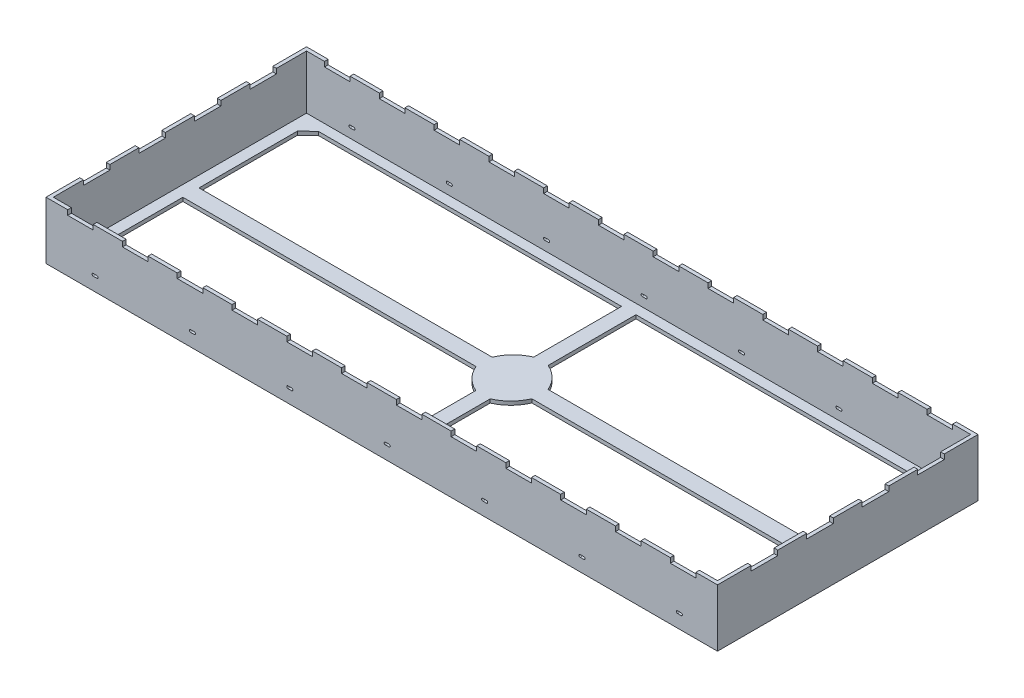
from build123d import *

# Parameters (mm, degrees)
SKETCH1_W           = 70.0532
SKETCH1_H           = 27.178
BOSS_EXTRUDE1_DEPTH = 5.9944
SHELL1_T            = -0.381
CUT_EXTRUDE1_DEPTH  = 6.9944
SKETCH3_W           = 2.667
SKETCH3_H           = 1.373025856
CUT_EXTRUDE2_DEPTH  = 28.178
SKETCH4_W           = 2.7686
SKETCH4_H           = 1.702359125
CUT_EXTRUDE3_DEPTH  = 71.0532
CUT_EXTRUDE4_DEPTH  = 28.178


with BuildPart() as part:
    # Sketch1 → Boss-Extrude1 (new body)
    with BuildSketch(Plane(origin=(0, 0, 0), x_dir=(1, 0, 0), z_dir=(0, 1, 0))):
        Rectangle(SKETCH1_W, SKETCH1_H)
    extrude(amount=BOSS_EXTRUDE1_DEPTH)

    # Shell1
    shell1_openings = [part.faces().sort_by_distance(p)[0] for p in [
        (0, 5.9944, 0),
    ]]
    offset(amount=SHELL1_T, openings=shell1_openings, kind=Kind.INTERSECTION)

    # Sketch2 → Cut-Extrude1 (cut, through all)
    with BuildSketch(Plane.XZ):
        with BuildLine():
            Line((-32.379973392, 12.180479984), (-0.752071146, 12.180479984))
            Line((-0.752071146, 12.180479984), (-0.752071146, 3.022683429))
            ThreePointArc((-0.752071146, 3.022683429), (-2.040283617, 2.139294884), (-2.913289687, 0.844023835))
            Line((-2.913289687, 0.844023835), (-33.49677785, 0.844023835))
            Line((-33.49677785, 0.844023835), (-33.49677785, 11.108347704))
            Line((-33.49677785, 11.108347704), (-32.379973392, 12.180479984))
        make_face()
        with BuildLine():
            Line((33.49677785, 0.844023835), (2.913289687, 0.844023835))
            ThreePointArc((2.913289687, 0.844023835), (2.040283617, 2.139294884), (0.752071146, 3.022683429))
            Line((0.752071146, 3.022683429), (0.752071146, 12.180479984))
            Line((0.752071146, 12.180479984), (32.379973392, 12.180479984))
            Line((32.379973392, 12.180479984), (33.49677785, 11.108347704))
            Line((33.49677785, 11.108347704), (33.49677785, 0.844023835))
        make_face()
        with BuildLine():
            Line((32.379973392, -12.180479984), (0.752071146, -12.180479984))
            Line((0.752071146, -12.180479984), (0.752071146, -3.022683429))
            ThreePointArc((0.752071146, -3.022683429), (2.040283617, -2.139294884), (2.913289687, -0.844023835))
            Line((2.913289687, -0.844023835), (33.49677785, -0.844023835))
            Line((33.49677785, -0.844023835), (33.49677785, -11.108347704))
            Line((33.49677785, -11.108347704), (32.379973392, -12.180479984))
        make_face()
        with BuildLine():
            Line((-33.49677785, -0.844023835), (-2.913289687, -0.844023835))
            ThreePointArc((-2.913289687, -0.844023835), (-2.040283617, -2.139294884), (-0.752071146, -3.022683429))
            Line((-0.752071146, -3.022683429), (-0.752071146, -12.180479984))
            Line((-0.752071146, -12.180479984), (-32.379973392, -12.180479984))
            Line((-32.379973392, -12.180479984), (-33.49677785, -11.108347704))
            Line((-33.49677785, -11.108347704), (-33.49677785, -0.844023835))
        make_face()
    extrude(amount=-CUT_EXTRUDE1_DEPTH, mode=Mode.SUBTRACT)

    # Sketch3 → Cut-Extrude2 (cut, through all)
    with BuildSketch(Plane(origin=(0, 0, -13.589), x_dir=(-1, 0, 0), z_dir=(0, 0, -1))):
        with Locations((-31.4325, 6.172912928)):
            Rectangle(SKETCH3_W, SKETCH3_H)
        with Locations((-25.7175, 6.172912928)):
            Rectangle(SKETCH3_W, SKETCH3_H)
        with Locations((-20.0025, 6.172912928)):
            Rectangle(SKETCH3_W, SKETCH3_H)
        with Locations((-14.2875, 6.172912928)):
            Rectangle(SKETCH3_W, SKETCH3_H)
        with Locations((-8.5725, 6.172912928)):
            Rectangle(SKETCH3_W, SKETCH3_H)
        with Locations((-2.8575, 6.172912928)):
            Rectangle(SKETCH3_W, SKETCH3_H)
        with Locations((2.8575, 6.172912928)):
            Rectangle(SKETCH3_W, SKETCH3_H)
        with Locations((8.5725, 6.172912928)):
            Rectangle(SKETCH3_W, SKETCH3_H)
        with Locations((14.2875, 6.172912928)):
            Rectangle(SKETCH3_W, SKETCH3_H)
        with Locations((20.0025, 6.172912928)):
            Rectangle(SKETCH3_W, SKETCH3_H)
        with Locations((25.7175, 6.172912928)):
            Rectangle(SKETCH3_W, SKETCH3_H)
        with Locations((31.4325, 6.172912928)):
            Rectangle(SKETCH3_W, SKETCH3_H)
    extrude(amount=-CUT_EXTRUDE2_DEPTH, mode=Mode.SUBTRACT)

    # Sketch4 → Cut-Extrude3 (cut, through all)
    with BuildSketch(Plane(origin=(35.0266, 0, 0), x_dir=(0, 0, -1), z_dir=(1, 0, 0))):
        with Locations((-8.6868, 6.337579563)):
            Rectangle(SKETCH4_W, SKETCH4_H)
        with Locations((-2.8956, 6.337579563)):
            Rectangle(SKETCH4_W, SKETCH4_H)
        with Locations((2.8956, 6.337579563)):
            Rectangle(SKETCH4_W, SKETCH4_H)
        with Locations((8.6868, 6.337579563)):
            Rectangle(SKETCH4_W, SKETCH4_H)
    extrude(amount=-CUT_EXTRUDE3_DEPTH, mode=Mode.SUBTRACT)

    # Sketch5 → Cut-Extrude4 (cut, through all)
    with BuildSketch(Plane(origin=(0, 0, -13.589), x_dir=(-1, 0, 0), z_dir=(0, 0, -1))):
        with BuildLine():
            Line((-31.242, 1.5748), (-30.861, 1.5748))
            ThreePointArc((-30.861, 1.5748), (-30.734, 1.4478), (-30.861, 1.3208))
            Line((-30.861, 1.3208), (-31.242, 1.3208))
            ThreePointArc((-31.242, 1.3208), (-31.369, 1.4478), (-31.242, 1.5748))
        make_face()
        with BuildLine():
            Line((-21.082, 1.5748), (-20.701, 1.5748))
            ThreePointArc((-20.701, 1.5748), (-20.574, 1.4478), (-20.701, 1.3208))
            Line((-20.701, 1.3208), (-21.082, 1.3208))
            ThreePointArc((-21.082, 1.3208), (-21.209, 1.4478), (-21.082, 1.5748))
        make_face()
        with BuildLine():
            Line((-10.922, 1.5748), (-10.541, 1.5748))
            ThreePointArc((-10.541, 1.5748), (-10.414, 1.4478), (-10.541, 1.3208))
            Line((-10.541, 1.3208), (-10.922, 1.3208))
            ThreePointArc((-10.922, 1.3208), (-11.049, 1.4478), (-10.922, 1.5748))
        make_face()
        with BuildLine():
            Line((-0.762, 1.5748), (-0.381, 1.5748))
            ThreePointArc((-0.381, 1.5748), (-0.254, 1.4478), (-0.381, 1.3208))
            Line((-0.381, 1.3208), (-0.762, 1.3208))
            ThreePointArc((-0.762, 1.3208), (-0.889, 1.4478), (-0.762, 1.5748))
        make_face()
        with BuildLine():
            Line((9.398, 1.5748), (9.779, 1.5748))
            ThreePointArc((9.779, 1.5748), (9.906, 1.4478), (9.779, 1.3208))
            Line((9.779, 1.3208), (9.398, 1.3208))
            ThreePointArc((9.398, 1.3208), (9.271, 1.4478), (9.398, 1.5748))
        make_face()
        with BuildLine():
            Line((19.558, 1.5748), (19.939, 1.5748))
            ThreePointArc((19.939, 1.5748), (20.066, 1.4478), (19.939, 1.3208))
            Line((19.939, 1.3208), (19.558, 1.3208))
            ThreePointArc((19.558, 1.3208), (19.431, 1.4478), (19.558, 1.5748))
        make_face()
        with BuildLine():
            Line((29.718, 1.5748), (30.099, 1.5748))
            ThreePointArc((30.099, 1.5748), (30.226, 1.4478), (30.099, 1.3208))
            Line((30.099, 1.3208), (29.718, 1.3208))
            ThreePointArc((29.718, 1.3208), (29.591, 1.4478), (29.718, 1.5748))
        make_face()
    extrude(amount=-CUT_EXTRUDE4_DEPTH, mode=Mode.SUBTRACT)


solid = part.part
